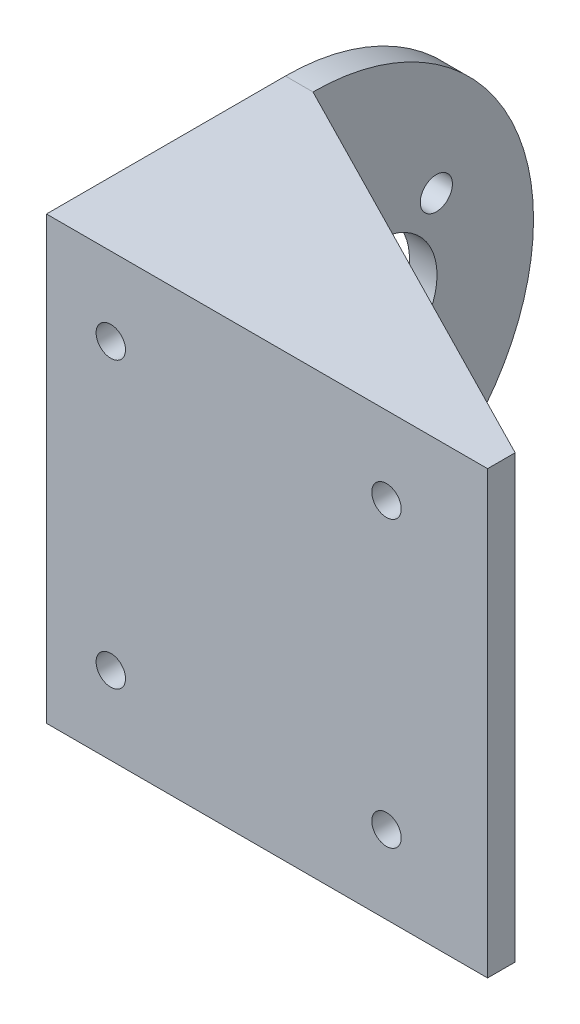
from build123d import *

# Parameters (mm, degrees)
SKETCH1_W           = 45
SKETCH1_H           = 48
SKETCH1_R           = 1.6
BOSS_EXTRUDE1_DEPTH = 3
BOSS_EXTRUDE2_DEPTH = 3
SKETCH4_R           = 6.5
SKETCH4_R_2         = 1.75
CUT_EXTRUDE1_DEPTH  = 10
BOSS_EXTRUDE3_DEPTH = 3
BOSS_EXTRUDE4_START = -48
BOSS_EXTRUDE4_DEPTH = 3


with BuildPart() as part:
    # Sketch1 → Boss-Extrude1 (new body)
    with BuildSketch(Plane.XY):
        with Locations((22.5, 24)):
            Rectangle(SKETCH1_W, SKETCH1_H)
        with Locations((4, 8.5)):
            Circle(SKETCH1_R, mode=Mode.SUBTRACT)
        with Locations((4, 39.5)):
            Circle(SKETCH1_R, mode=Mode.SUBTRACT)
        with Locations((34, 8.5)):
            Circle(SKETCH1_R, mode=Mode.SUBTRACT)
        with Locations((34, 39.5)):
            Circle(SKETCH1_R, mode=Mode.SUBTRACT)
    extrude(amount=BOSS_EXTRUDE1_DEPTH)

    # Sketch2 → Boss-Extrude2 (add)
    with BuildSketch(Plane.ZY):
        with BuildLine():
            Line((3, 48), (-23, 48))
            ThreePointArc((-23, 48), (-47, 24), (-23, 0))
            Line((-23, 0), (3, 0))
            Line((3, 0), (3, 48))
        make_face()
    extrude(amount=BOSS_EXTRUDE2_DEPTH)

    # Sketch4 → Cut-Extrude1 (cut)
    with BuildSketch(Plane.ZY.offset(3)):
        with Locations((-30, 24)):
            Circle(SKETCH4_R)
        with Locations((-23, 39.5)):
            Circle(SKETCH4_R_2)
        with Locations((-9.576606241, 31.75)):
            Circle(SKETCH4_R_2)
        with Locations((-9.576606241, 16.25)):
            Circle(SKETCH4_R_2)
        with Locations((-23, 8.5)):
            Circle(SKETCH4_R_2)
        with Locations((-36.423393759, 16.25)):
            Circle(SKETCH4_R_2)
        with Locations((-36.423393759, 31.75)):
            Circle(SKETCH4_R_2)
    extrude(amount=-CUT_EXTRUDE1_DEPTH, mode=Mode.SUBTRACT)

    # Sketch5 → Boss-Extrude3 (add)
    with BuildSketch(Plane(origin=(0, 48, 0), x_dir=(1, 0, 0), z_dir=(0, 1, 0))):
        Polygon((0, 23), (45, 0), (0, 0), align=None)
    extrude(amount=-BOSS_EXTRUDE3_DEPTH)

    # Sketch5_2 → Boss-Extrude4 (add)
    with BuildSketch(Plane(origin=(0, 48, 0), x_dir=(1, 0, 0), z_dir=(0, 1, 0)).offset(BOSS_EXTRUDE4_START)):
        Polygon((0, 23), (45, 0), (0, 0), align=None)
    extrude(amount=BOSS_EXTRUDE4_DEPTH)


solid = part.part
